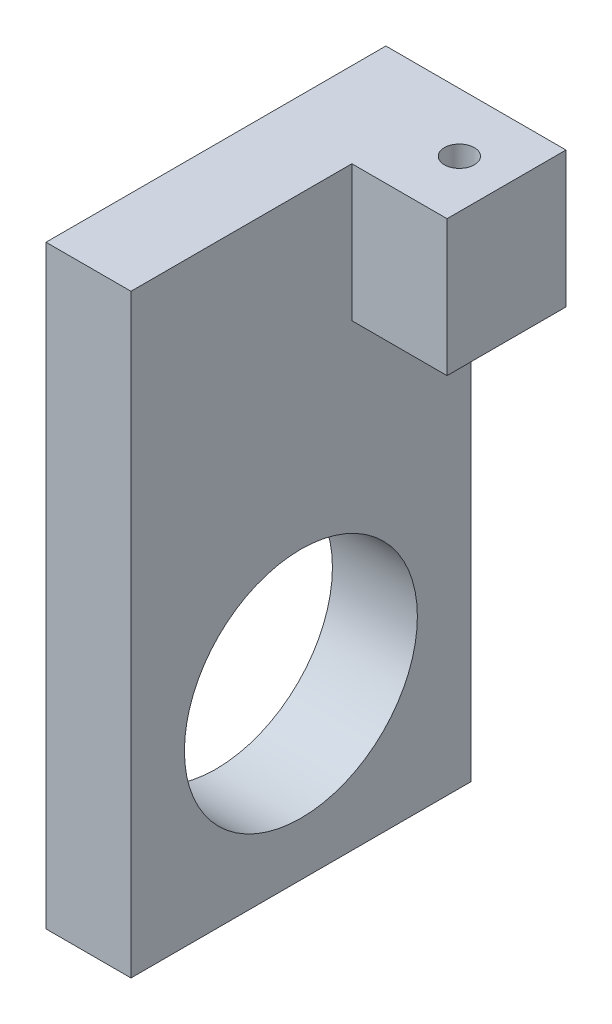
from build123d import *

# Parameters (mm, degrees)
SKETCH1_W           = 6.35
SKETCH1_H           = 44.45
BOSS_EXTRUDE1_DEPTH = 25.4
SKETCH2_W           = 8.89
SKETCH2_H           = 10.16
BOSS_EXTRUDE2_DEPTH = 7.112
SKETCH4_R           = 6.441586538
CUT_EXTRUDE1_DEPTH  = 6.35
CUT_EXTRUDE2_REACH  = 41.953
SKETCH3_R           = 8.70585
SKETCH5_R           = 1.1176
SKETCH5_R_2         = 0.9906
CUT_EXTRUDE3_DEPTH  = 10.16


with BuildPart() as part:
    # Sketch1 → Boss-Extrude1 (new body)
    with BuildSketch(Plane.XY.offset(-3.193523187)):
        with Locations((-5.550476906, -10.21740419)):
            Rectangle(SKETCH1_W, SKETCH1_H)
    extrude(amount=BOSS_EXTRUDE1_DEPTH)

    # Sketch2 → Boss-Extrude2 (add)
    with BuildSketch(Plane(origin=(-2.375476906, 0, 0), x_dir=(0, 0, -1), z_dir=(1, 0, 0))):
        with Locations((-1.251476813, 6.92759581)):
            Rectangle(SKETCH2_W, SKETCH2_H)
    extrude(amount=BOSS_EXTRUDE2_DEPTH)

    # Sketch4 → Cut-Extrude1 (cut)
    with BuildSketch(Plane(origin=(-2.375476906, 0, 0), x_dir=(0, 0, -1), z_dir=(1, 0, 0))):
        with Locations(Location((-9.506476813, -19.74240419, 0), (0, 0, 90))):
            Circle(SKETCH4_R)
    extrude(amount=-CUT_EXTRUDE1_DEPTH, mode=Mode.SUBTRACT)

    # Sketch3 → Cut-Extrude2 (cut, up to next)
    with BuildSketch(Plane(origin=(-2.375476906, 0, 0), x_dir=(0, 0, -1), z_dir=(1, 0, 0)), mode=Mode.PRIVATE) as cut_extrude2_sk1:
        with Locations(Location((-9.506476813, -19.74240419, 0), (0, 0, 90))):
            Circle(SKETCH3_R)
    cut_extrude2_tool1 = extrude(cut_extrude2_sk1.sketch, amount=-CUT_EXTRUDE2_REACH, mode=Mode.PRIVATE) & part.part
    add(cut_extrude2_tool1.solids().sort_by_distance((-2.375477, -19.742404, 9.506477))[0], mode=Mode.SUBTRACT)

    # Sketch5 → Cut-Extrude3 (cut)
    with BuildSketch(Plane(origin=(0, 12.00759581, 0), x_dir=(1, 0, 0), z_dir=(0, 1, 0))):
        with Locations(Location((1.155123094, -1.192963507, 0), (0, 0, 270))):
            Circle(SKETCH5_R)
        with Locations((1.155123094, -1.192963507)):
            Circle(SKETCH5_R_2, mode=Mode.SUBTRACT)
        with Locations((1.155123094, -1.192963507)):
            Circle(SKETCH5_R_2)
    extrude(amount=-CUT_EXTRUDE3_DEPTH, mode=Mode.SUBTRACT)


solid = part.part
